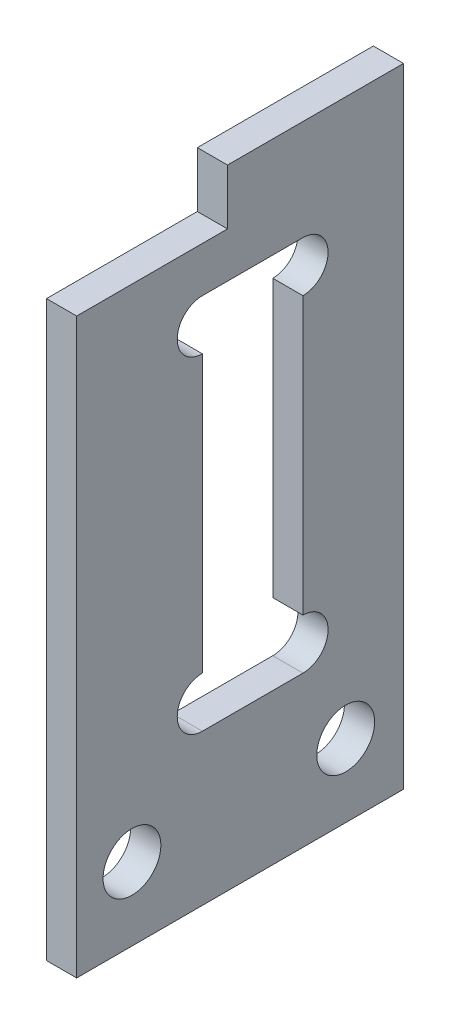
from build123d import *

# Parameters (mm, degrees)
SKETCH_1_W          = 15
SKETCH_1_H          = 25
EXTRUDE_1_DEPTH     = 1.2
CUT_EXTRUDE_1_REACH = 3.2
SKETCH_2_R          = 1.15
SKETCH_2_W          = 6
SKETCH_2_H          = 2.2
SKETCH_2_W_2        = 2
SKETCH_2_H_2        = 17
SKETCH_3_W          = 2
SKETCH_3_H          = 5
CUT_EXTRUDE_2_DEPTH = 2.2
SKETCH_4_W          = 2
SKETCH_4_H          = 3
CUT_EXTRUDE_3_DEPTH = 2.2


with BuildPart() as part:
    # Эскиз1 → Вытянуть1 (new body)
    with BuildSketch(Plane(origin=(0, 0, 0), x_dir=(0, 0, -1), z_dir=(1, 0, 0))):
        with Locations((7.5, 12.5)):
            Rectangle(SKETCH_1_W, SKETCH_1_H)
    extrude(amount=EXTRUDE_1_DEPTH)

    # Эскиз2 → Вырез-Вытянуть1 (cut, up to next)
    with BuildSketch(Plane(origin=(1.2, 0, 0), x_dir=(0, 0, -1), z_dir=(1, 0, 0)), mode=Mode.PRIVATE) as cut_extrude_1_sk1:
        with Locations((10.7, 2.9)):
            Circle(SKETCH_2_R)
    cut_extrude_1_tool1 = extrude(cut_extrude_1_sk1.sketch, amount=-CUT_EXTRUDE_1_REACH, mode=Mode.PRIVATE) & part.part
    add(cut_extrude_1_tool1.solids().sort_by_distance((1.2, 2.9, -10.7))[0], mode=Mode.SUBTRACT)
    # Эскиз2 → Вырез-Вытянуть1 (cut, up to next)
    with BuildSketch(Plane(origin=(1.2, 0, 0), x_dir=(0, 0, -1), z_dir=(1, 0, 0)), mode=Mode.PRIVATE) as cut_extrude_1_sk2:
        with Locations((2.2, 2.9)):
            Circle(SKETCH_2_R)
    cut_extrude_1_tool2 = extrude(cut_extrude_1_sk2.sketch, amount=-CUT_EXTRUDE_1_REACH, mode=Mode.PRIVATE) & part.part
    add(cut_extrude_1_tool2.solids().sort_by_distance((1.2, 2.9, -2.2))[0], mode=Mode.SUBTRACT)
    # Эскиз2 → Вырез-Вытянуть1 (cut, up to next)
    with BuildSketch(Plane(origin=(1.2, 0, 0), x_dir=(0, 0, -1), z_dir=(1, 0, 0)), mode=Mode.PRIVATE) as cut_extrude_1_sk3:
        with Locations((3, 23.9)):
            Rectangle(SKETCH_2_W, SKETCH_2_H)
    cut_extrude_1_tool3 = extrude(cut_extrude_1_sk3.sketch, amount=-CUT_EXTRUDE_1_REACH, mode=Mode.PRIVATE) & part.part
    add(cut_extrude_1_tool3.solids().sort_by_distance((1.2, 23.9, -3))[0], mode=Mode.SUBTRACT)
    # Эскиз2 → Вырез-Вытянуть1 (cut, up to next)
    with BuildSketch(Plane(origin=(1.2, 0, 0), x_dir=(0, 0, -1), z_dir=(1, 0, 0)), mode=Mode.PRIVATE) as cut_extrude_1_sk4:
        with BuildLine():
            Line((5, 6), (9, 6))
            ThreePointArc((9, 6), (10, 7), (9, 8))
            Line((9, 8), (9, 19))
            ThreePointArc((9, 19), (10, 20), (9, 21))
            Line((9, 21), (5, 21))
            ThreePointArc((5, 21), (4, 20), (5, 19))
            Line((5, 19), (5, 8))
            ThreePointArc((5, 8), (4, 7), (5, 6))
        make_face()
    cut_extrude_1_tool4 = extrude(cut_extrude_1_sk4.sketch, amount=-CUT_EXTRUDE_1_REACH, mode=Mode.PRIVATE) & part.part
    add(cut_extrude_1_tool4.solids().sort_by_distance((1.2, 13.5, -7))[0], mode=Mode.SUBTRACT)
    # Эскиз2 → Вырез-Вытянуть1 (cut, up to next)
    with BuildSketch(Plane(origin=(1.2, 0, 0), x_dir=(0, 0, -1), z_dir=(1, 0, 0)), mode=Mode.PRIVATE) as cut_extrude_1_sk5:
        with Locations((14, 13.5)):
            Rectangle(SKETCH_2_W_2, SKETCH_2_H_2)
    cut_extrude_1_tool5 = extrude(cut_extrude_1_sk5.sketch, amount=-CUT_EXTRUDE_1_REACH, mode=Mode.PRIVATE) & part.part
    add(cut_extrude_1_tool5.solids().sort_by_distance((1.2, 13.5, -14))[0], mode=Mode.SUBTRACT)

    # Эскиз3 → Вырез-Вытянуть2 (cut, through all)
    with BuildSketch(Plane(origin=(1.2, 0, 0), x_dir=(0, 0, -1), z_dir=(1, 0, 0))):
        with Locations((14, 2.5)):
            Rectangle(SKETCH_3_W, SKETCH_3_H)
    extrude(amount=-CUT_EXTRUDE_2_DEPTH, mode=Mode.SUBTRACT)

    # Эскиз4 → Вырез-Вытянуть3 (cut, through all)
    with BuildSketch(Plane(origin=(1.2, 0, 0), x_dir=(0, 0, -1), z_dir=(1, 0, 0))):
        with Locations((14, 23.5)):
            Rectangle(SKETCH_4_W, SKETCH_4_H)
    extrude(amount=-CUT_EXTRUDE_3_DEPTH, mode=Mode.SUBTRACT)


solid = part.part
